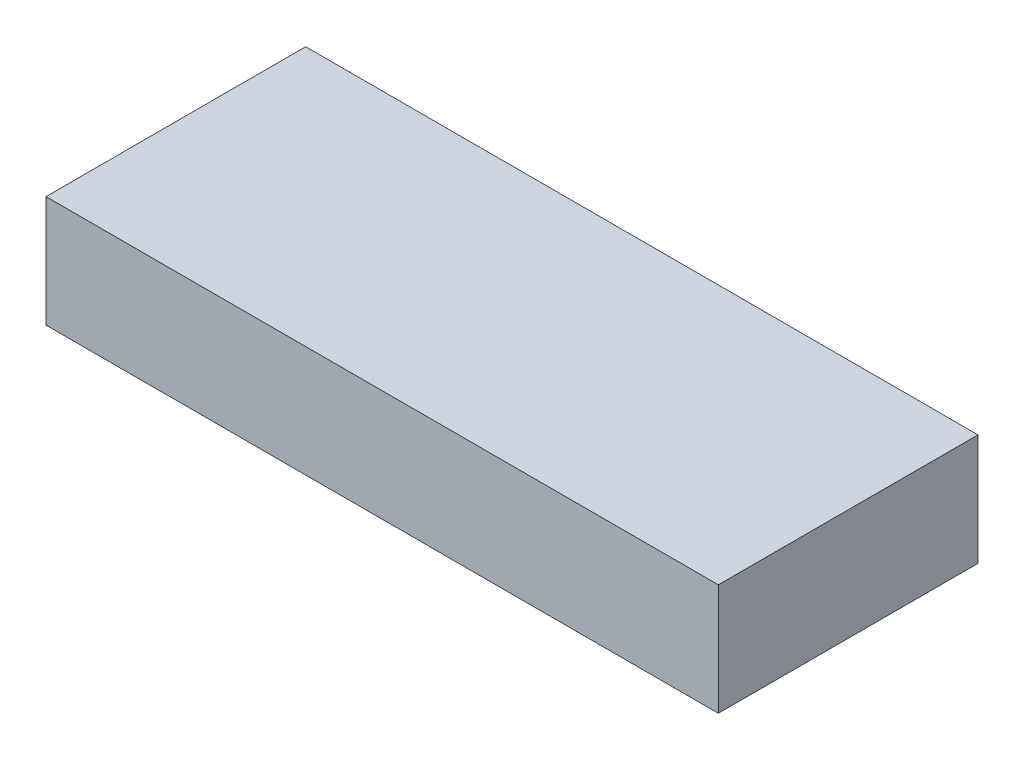
from build123d import *

# Parameters (mm, degrees)
SKETCH1_W           = 230.1875
SKETCH1_H           = 88.9
BOSS_EXTRUDE1_DEPTH = 38.1


with BuildPart() as part:
    # Sketch1 → Boss-Extrude1 (new body)
    with BuildSketch(Plane(origin=(0, 0, 0), x_dir=(1, 0, 0), z_dir=(0, 1, 0))):
        with Locations((115.09375, 44.45)):
            Rectangle(SKETCH1_W, SKETCH1_H)
    extrude(amount=BOSS_EXTRUDE1_DEPTH)


solid = part.part
